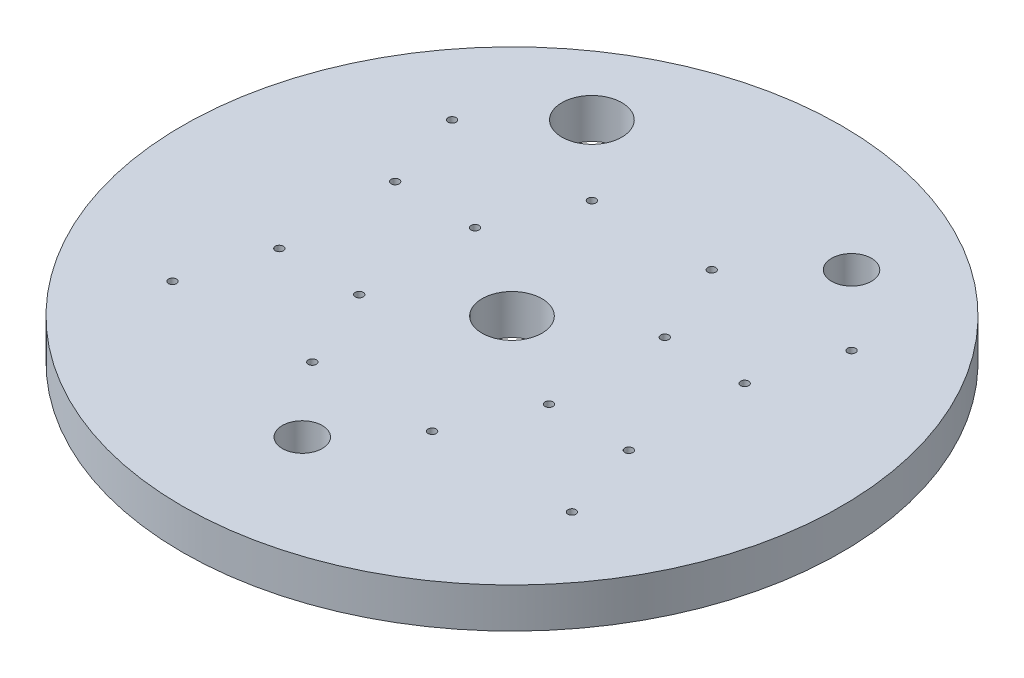
from build123d import *

# Parameters (mm, degrees)
SKETCH1_R                        = 209.55
BOSS_EXTRUDE1_DEPTH              = 12.7
F_3_8_16_TAPPED_HOLE1_D          = 7.9375
F_3_8_16_TAPPED_HOLE1_DEPTH      = 19.304
F_3_8_16_TAPPED_HOLE1_TIP        = 2.384665582
CUT_EXTRUDE1_REACH               = 27.4
SKETCH4_R                        = 19.05
CUT_EXTRUDE2_REACH               = 27.4
SKETCH5_R                        = 12.7
CUT_EXTRUDE3_REACH               = 27.4
SKETCH6_R                        = 19.05
F_1_4_20_TAPPED_HOLE1_AT_2_COUNT = 2
F_1_4_20_TAPPED_HOLE1_AT_2_PITCH = 50.8
F_1_4_20_TAPPED_HOLE2_AT_2_COUNT = 2
F_1_4_20_TAPPED_HOLE2_AT_2_PITCH = 88.9
F_1_4_20_TAPPED_HOLE3_AT_2_COUNT = 2
F_1_4_20_TAPPED_HOLE3_AT_2_PITCH = 50.8
F_1_4_20_TAPPED_HOLE3_AT_3_COUNT = 2
F_1_4_20_TAPPED_HOLE3_AT_3_PITCH = 71.842048969
F_1_4_20_TAPPED_HOLE3_AT_4_COUNT = 2
F_1_4_20_TAPPED_HOLE3_AT_4_PITCH = 50.8


with BuildPart() as part:
    # Sketch1 → Boss-Extrude1 (new body, symmetric)
    with BuildSketch(Plane(origin=(0, 0, 0), x_dir=(1, 0, 0), z_dir=(0, 1, 0))):
        Circle(SKETCH1_R)
    extrude(amount=BOSS_EXTRUDE1_DEPTH, both=True)

    # 3/8-16 Tapped Hole1
    with Locations(Plane(origin=(0, -12.7, 0), x_dir=(-1, 0, 0), z_dir=(0, -1, 0))):
        with Locations((88.9, -88.9), (-88.9, -88.9), (-88.9, 88.9), (88.9, 88.9)):
            Hole(F_3_8_16_TAPPED_HOLE1_D / 2, depth=F_3_8_16_TAPPED_HOLE1_DEPTH)
            with Locations((0, 0, -(F_3_8_16_TAPPED_HOLE1_DEPTH + F_3_8_16_TAPPED_HOLE1_TIP / 2))):  # 118° drill point
                Cone(0, F_3_8_16_TAPPED_HOLE1_D / 2, F_3_8_16_TAPPED_HOLE1_TIP, mode=Mode.SUBTRACT)

    # Sketch4 → Cut-Extrude1 (cut, up to next)
    with BuildSketch(Plane(origin=(0, 12.7, 0), x_dir=(1, 0, 0), z_dir=(0, 1, 0)), mode=Mode.PRIVATE) as cut_extrude1_sk1:
        Circle(SKETCH4_R)
    cut_extrude1_tool1 = extrude(cut_extrude1_sk1.sketch, amount=-CUT_EXTRUDE1_REACH, mode=Mode.PRIVATE) & part.part
    add(cut_extrude1_tool1.solids().sort_by_distance((0, 12.7, 0))[0], mode=Mode.SUBTRACT)

    # Sketch5 → Cut-Extrude2 (cut, up to next)
    with BuildSketch(Plane(origin=(0, 12.7, 0), x_dir=(1, 0, 0), z_dir=(0, 1, 0)), mode=Mode.PRIVATE) as cut_extrude2_sk1:
        with Locations((0, -133.35)):
            Circle(SKETCH5_R)
    cut_extrude2_tool1 = extrude(cut_extrude2_sk1.sketch, amount=-CUT_EXTRUDE2_REACH, mode=Mode.PRIVATE) & part.part
    add(cut_extrude2_tool1.solids().sort_by_distance((0, 12.7, 133.35))[0], mode=Mode.SUBTRACT)
    # Sketch5 → Cut-Extrude2 (cut, up to next)
    with BuildSketch(Plane(origin=(0, 12.7, 0), x_dir=(1, 0, 0), z_dir=(0, 1, 0)), mode=Mode.PRIVATE) as cut_extrude2_sk2:
        with Locations((82.55, 133.35)):
            Circle(SKETCH5_R)
    cut_extrude2_tool2 = extrude(cut_extrude2_sk2.sketch, amount=-CUT_EXTRUDE2_REACH, mode=Mode.PRIVATE) & part.part
    add(cut_extrude2_tool2.solids().sort_by_distance((82.55, 12.7, -133.35))[0], mode=Mode.SUBTRACT)

    # Sketch6 → Cut-Extrude3 (cut, up to next)
    with BuildSketch(Plane(origin=(0, 12.7, 0), x_dir=(1, 0, 0), z_dir=(0, 1, 0)), mode=Mode.PRIVATE) as cut_extrude3_sk1:
        with Locations((-82.55, 133.35)):
            Circle(SKETCH6_R)
    cut_extrude3_tool1 = extrude(cut_extrude3_sk1.sketch, amount=-CUT_EXTRUDE3_REACH, mode=Mode.PRIVATE) & part.part
    add(cut_extrude3_tool1.solids().sort_by_distance((-82.55, 12.7, -133.35))[0], mode=Mode.SUBTRACT)

    # Sketch7 → 1/4-20 Tapped Hole1 (revolve, cut)
    with BuildSketch(Plane(origin=(-111.125, 12.7, -36.83), x_dir=(0, 0, 1), z_dir=(1, 0, 0))):
        Polygon((0, 0), (0, 20.583816902), (2.5527, 19.05), (2.5527, 0), align=None)
    f_1_4_20_tapped_hole1 = revolve(axis=Axis((-111.125, 19.05, -36.83), (0, -1, 0)), mode=Mode.SUBTRACT)

    # 1/4-20 Tapped Hole1 at 2: 1/4-20 Tapped Hole1 ×2
    with Locations(*[(i * F_1_4_20_TAPPED_HOLE1_AT_2_PITCH, 0, 0) for i in range(1, F_1_4_20_TAPPED_HOLE1_AT_2_COUNT)]):
        add(f_1_4_20_tapped_hole1, mode=Mode.SUBTRACT)

    # Sketch9 → 1/4-20 Tapped Hole2 (revolve, cut)
    with BuildSketch(Plane(origin=(-38.1, 12.7, -88.9), x_dir=(0, 0, 1), z_dir=(1, 0, 0))):
        Polygon((0, 0), (0, 20.583816902), (2.5527, 19.05), (2.5527, 0), align=None)
    f_1_4_20_tapped_hole2 = revolve(axis=Axis((-38.1, 19.05, -88.9), (0, -1, 0)), mode=Mode.SUBTRACT)

    # 1/4-20 Tapped Hole2 at 2: 1/4-20 Tapped Hole2 ×2
    with Locations(*[(-i * F_1_4_20_TAPPED_HOLE2_AT_2_PITCH, 0, 0) for i in range(1, F_1_4_20_TAPPED_HOLE2_AT_2_COUNT)]):
        add(f_1_4_20_tapped_hole2, mode=Mode.SUBTRACT)

    # Mirror1: 1/4-20 Tapped Hole2, 1/4-20 Tapped Hole1 across plane
    add(f_1_4_20_tapped_hole2.mirror(Plane(origin=(0, 0, 0), x_dir=(0, 0, 1), z_dir=(1, 0, 0))), mode=Mode.SUBTRACT)
    add(f_1_4_20_tapped_hole1.mirror(Plane(origin=(0, 0, 0), x_dir=(0, 0, 1), z_dir=(1, 0, 0))), mode=Mode.SUBTRACT)

    # Mirror1 copy 1 sketch → Mirror1 copy 1 (revolve, cut)
    with BuildSketch(Plane(origin=(127, 12.7, -88.9), x_dir=(0, 0, 1), z_dir=(-1, 0, 0))):
        Polygon((0, 0), (0, -20.583816902), (2.5527, -19.05), (2.5527, 0), align=None)
    revolve(axis=Axis((127, 19.05, -88.9), (0, 1, 0)), mode=Mode.SUBTRACT)

    # Mirror1 copy 2 sketch → Mirror1 copy 2 (revolve, cut)
    with BuildSketch(Plane(origin=(60.325, 12.7, -36.83), x_dir=(0, 0, 1), z_dir=(-1, 0, 0))):
        Polygon((0, 0), (0, -20.583816902), (2.5527, -19.05), (2.5527, 0), align=None)
    revolve(axis=Axis((60.325, 19.05, -36.83), (0, 1, 0)), mode=Mode.SUBTRACT)

    # Mirror2: 1/4-20 Tapped Hole2, 1/4-20 Tapped Hole1 across plane
    add(f_1_4_20_tapped_hole2.mirror(Plane.XY), mode=Mode.SUBTRACT)
    add(f_1_4_20_tapped_hole1.mirror(Plane.XY), mode=Mode.SUBTRACT)

    # Mirror2 copy 1 sketch → Mirror2 copy 1 (revolve, cut)
    with BuildSketch(Plane(origin=(38.1, 12.7, 88.9), x_dir=(0, 0, -1), z_dir=(-1, 0, 0))):
        Polygon((0, 0), (0, 20.583816902), (2.5527, 19.05), (2.5527, 0), align=None)
    revolve(axis=Axis((38.1, 19.05, 88.9), (0, -1, 0)), mode=Mode.SUBTRACT)

    # Mirror2 copy 2 sketch → Mirror2 copy 2 (revolve, cut)
    with BuildSketch(Plane(origin=(111.125, 12.7, 36.83), x_dir=(0, 0, -1), z_dir=(-1, 0, 0))):
        Polygon((0, 0), (0, 20.583816902), (2.5527, 19.05), (2.5527, 0), align=None)
    revolve(axis=Axis((111.125, 19.05, 36.83), (0, -1, 0)), mode=Mode.SUBTRACT)

    # Mirror2 copy 3 sketch → Mirror2 copy 3 (revolve, cut)
    with BuildSketch(Plane(origin=(127, 12.7, 88.9), x_dir=(0, 0, -1), z_dir=(-1, 0, 0))):
        Polygon((0, 0), (0, 20.583816902), (2.5527, 19.05), (2.5527, 0), align=None)
    revolve(axis=Axis((127, 19.05, 88.9), (0, -1, 0)), mode=Mode.SUBTRACT)

    # Mirror2 copy 4 sketch → Mirror2 copy 4 (revolve, cut)
    with BuildSketch(Plane(origin=(60.325, 12.7, 36.83), x_dir=(0, 0, -1), z_dir=(-1, 0, 0))):
        Polygon((0, 0), (0, 20.583816902), (2.5527, 19.05), (2.5527, 0), align=None)
    revolve(axis=Axis((60.325, 19.05, 36.83), (0, -1, 0)), mode=Mode.SUBTRACT)

    # Mirror2 copy 5 sketch → Mirror2 copy 5 (revolve, cut)
    with BuildSketch(Plane(origin=(-127, 12.7, 88.9), x_dir=(0, 0, -1), z_dir=(1, 0, 0))):
        Polygon((0, 0), (0, -20.583816902), (2.5527, -19.05), (2.5527, 0), align=None)
    revolve(axis=Axis((-127, 19.05, 88.9), (0, 1, 0)), mode=Mode.SUBTRACT)

    # Mirror2 copy 6 sketch → Mirror2 copy 6 (revolve, cut)
    with BuildSketch(Plane(origin=(-60.325, 12.7, 36.83), x_dir=(0, 0, -1), z_dir=(1, 0, 0))):
        Polygon((0, 0), (0, -20.583816902), (2.5527, -19.05), (2.5527, 0), align=None)
    revolve(axis=Axis((-60.325, 19.05, 36.83), (0, 1, 0)), mode=Mode.SUBTRACT)

    # Sketch12 → 1/4-20 Tapped Hole3 (revolve, cut)
    with BuildSketch(Plane(origin=(-177.8, -12.7, 25.4), x_dir=(0, 0, -1), z_dir=(1, 0, 0))):
        Polygon((0, 0), (0, 20.583816902), (2.5527, 19.05), (2.5527, 0), align=None)
    f_1_4_20_tapped_hole3 = revolve(axis=Axis((-177.8, -19.05, 25.4), (0, 1, 0)), mode=Mode.SUBTRACT)

    # 1/4-20 Tapped Hole3 at 2: 1/4-20 Tapped Hole3 ×2
    with Locations(*[(i * F_1_4_20_TAPPED_HOLE3_AT_2_PITCH, 0, 0) for i in range(1, F_1_4_20_TAPPED_HOLE3_AT_2_COUNT)]):
        add(f_1_4_20_tapped_hole3, mode=Mode.SUBTRACT)

    # 1/4-20 Tapped Hole3 at 3: 1/4-20 Tapped Hole3 ×2
    with Locations(*[Vector(0.707106781, 0, -0.707106781) * (i * F_1_4_20_TAPPED_HOLE3_AT_3_PITCH) for i in range(1, F_1_4_20_TAPPED_HOLE3_AT_3_COUNT)]):
        add(f_1_4_20_tapped_hole3, mode=Mode.SUBTRACT)

    # 1/4-20 Tapped Hole3 at 4: 1/4-20 Tapped Hole3 ×2
    with Locations(*[(0, 0, -i * F_1_4_20_TAPPED_HOLE3_AT_4_PITCH) for i in range(1, F_1_4_20_TAPPED_HOLE3_AT_4_COUNT)]):
        add(f_1_4_20_tapped_hole3, mode=Mode.SUBTRACT)

    # Mirror3: 1/4-20 Tapped Hole3 across plane
    add(f_1_4_20_tapped_hole3.mirror(Plane(origin=(0, 0, 0), x_dir=(0, 0, 1), z_dir=(1, 0, 0))), mode=Mode.SUBTRACT)

    # Mirror3 copy 1 sketch → Mirror3 copy 1 (revolve, cut)
    with BuildSketch(Plane(origin=(127, -12.7, 25.4), x_dir=(0, 0, -1), z_dir=(-1, 0, 0))):
        Polygon((0, 0), (0, -20.583816902), (2.5527, -19.05), (2.5527, 0), align=None)
    revolve(axis=Axis((127, -19.05, 25.4), (0, -1, 0)), mode=Mode.SUBTRACT)

    # Mirror3 copy 2 sketch → Mirror3 copy 2 (revolve, cut)
    with BuildSketch(Plane(origin=(127, -12.7, -25.4), x_dir=(0, 0, -1), z_dir=(-1, 0, 0))):
        Polygon((0, 0), (0, -20.583816902), (2.5527, -19.05), (2.5527, 0), align=None)
    revolve(axis=Axis((127, -19.05, -25.4), (0, -1, 0)), mode=Mode.SUBTRACT)

    # Mirror3 copy 3 sketch → Mirror3 copy 3 (revolve, cut)
    with BuildSketch(Plane(origin=(177.8, -12.7, -25.4), x_dir=(0, 0, -1), z_dir=(-1, 0, 0))):
        Polygon((0, 0), (0, -20.583816902), (2.5527, -19.05), (2.5527, 0), align=None)
    revolve(axis=Axis((177.8, -19.05, -25.4), (0, -1, 0)), mode=Mode.SUBTRACT)


solid = part.part
